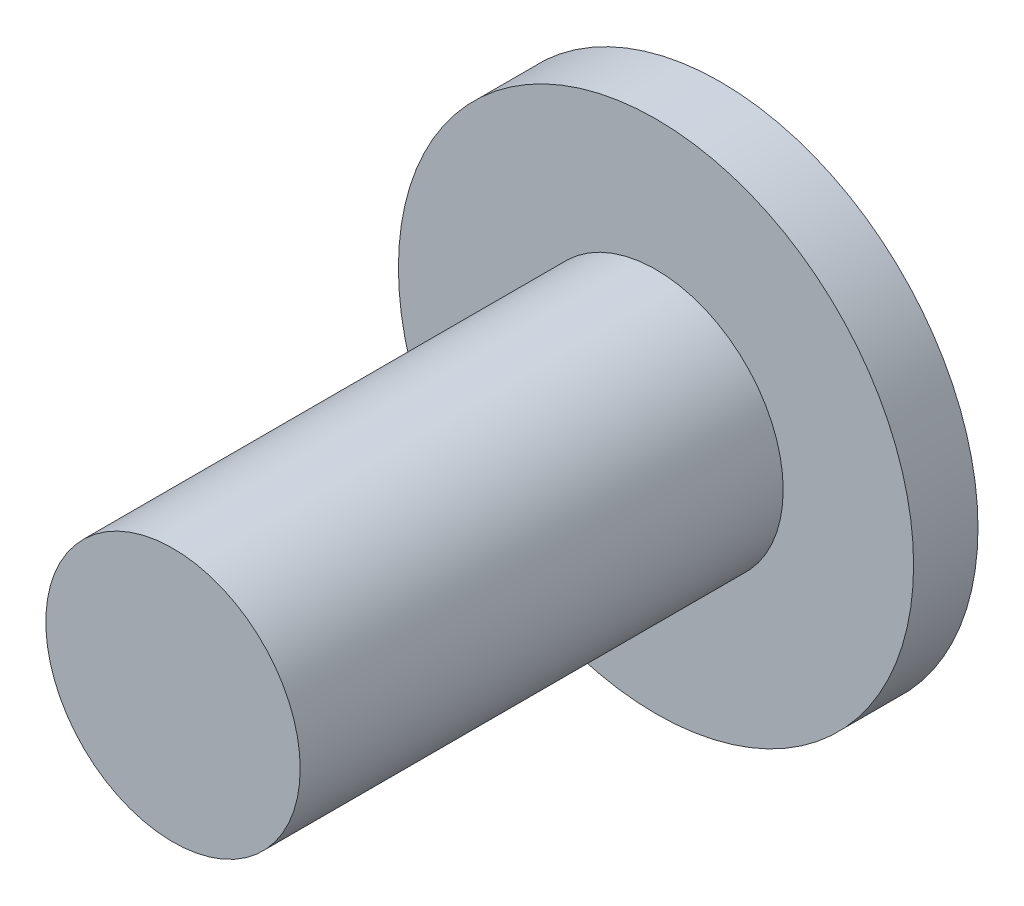
from build123d import *

# Parameters (mm, degrees)
SKETCH1_W   = 3.95
SKETCH1_H   = 15
SKETCH1_W_2 = 8
SKETCH1_H_2 = 2


with BuildPart() as part:
    # Sketch1 → Revolve1 (revolve)
    with BuildSketch(Plane(origin=(0, 0, 0), x_dir=(1, 0, 0), z_dir=(0, 1, 0))):
        with Locations((1.975, 7.5)):
            Rectangle(SKETCH1_W, SKETCH1_H)
        with Locations((4, 16)):
            Rectangle(SKETCH1_W_2, SKETCH1_H_2)
    revolve(axis=Axis((0, 0, 0), (0, 0, -1)))


solid = part.part
